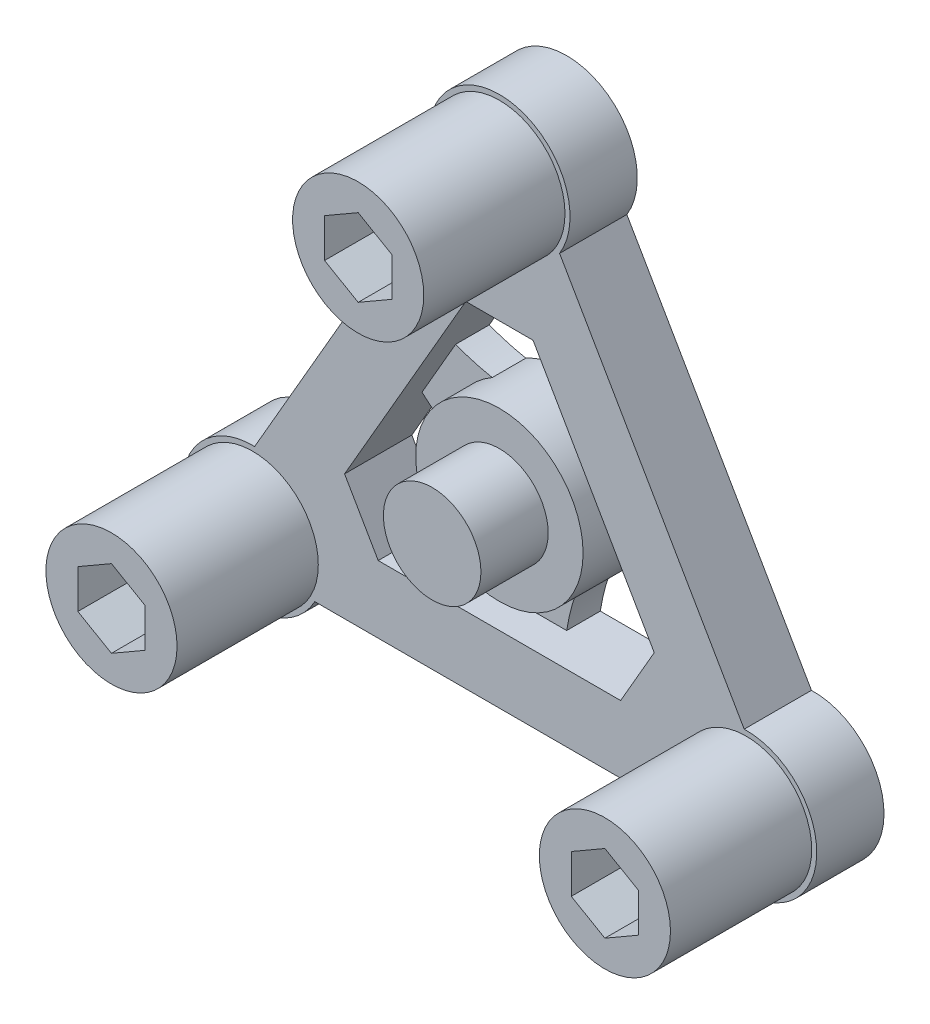
from build123d import *

# Parameters (mm, degrees)
BOSS_EXTRUDE1_DEPTH = 5
BOSS_EXTRUDE2_DEPTH = 5
SKETCH4_R           = 9.75
BOSS_EXTRUDE3_DEPTH = 21
BOSS_EXTRUDE4_START = -5
SKETCH5_R           = 12.441578391
BOSS_EXTRUDE4_DEPTH = 10
SKETCH5_3_R         = 7.25
BOSS_EXTRUDE5_DEPTH = 15
CHAMFER1_SIZE       = 10
CUT_EXTRUDE1_DEPTH  = 10
CUT_EXTRUDE2_DEPTH  = 4.2


with BuildPart() as part:
    # Sketch2 → Boss-Extrude1 (new body, symmetric)
    with BuildSketch(Plane.XY):
        with BuildLine():
            ThreePointArc((8.946673347, 36.860907204), (0, 52.857), (-8.946673347, 36.860907204))
            Line((-8.946673347, 36.860907204), (-36.395818719, -10.682407204))
            ThreePointArc((-36.395818719, -10.682407204), (-45.775504768, -26.4285), (-27.449145372, -26.1785))
            Line((-27.449145372, -26.1785), (27.449145372, -26.1785))
            ThreePointArc((27.449145372, -26.1785), (45.775504768, -26.4285), (36.395818719, -10.682407204))
            Line((36.395818719, -10.682407204), (8.946673347, 36.860907204))
        make_face()
        Polygon((-28.02198399, -16.1785), (0, 32.357), (28.02198399, -16.1785), align=None, mode=Mode.SUBTRACT)
    extrude(amount=BOSS_EXTRUDE1_DEPTH, both=True)

    # Sketch3 → Boss-Extrude2 (add)
    with BuildSketch(Plane.XY):
        with BuildLine():
            Line((-16.510991995, 3.759122981), (-11.510991995, 12.419377019))
            ThreePointArc((-11.510991995, 12.419377019), (0, 10.282645658), (11.510991995, 12.419377019))
            Line((11.510991995, 12.419377019), (16.510991995, 3.759122981))
            ThreePointArc((16.510991995, 3.759122981), (8.905032358, -5.141322829), (5, -16.1785))
            Line((5, -16.1785), (-5, -16.1785))
            ThreePointArc((-5, -16.1785), (-8.905032358, -5.141322829), (-16.510991995, 3.759122981))
        make_face()
    extrude(amount=-BOSS_EXTRUDE2_DEPTH)

    # Sketch4 → Boss-Extrude3 (add)
    with BuildSketch(Plane.XY.offset(5)):
        with Locations((-36.682238028, -21.1785)):
            Circle(SKETCH4_R)
        with Locations((36.682238028, -21.1785)):
            Circle(SKETCH4_R)
        with Locations((0, 42.357)):
            Circle(SKETCH4_R)
    extrude(amount=BOSS_EXTRUDE3_DEPTH)

    # Sketch5 → Boss-Extrude4 (add)
    with BuildSketch(Plane.XY.offset(BOSS_EXTRUDE4_START)):
        Circle(SKETCH5_R)
    extrude(amount=BOSS_EXTRUDE4_DEPTH)

    # Sketch5_3 → Boss-Extrude5 (add)
    with BuildSketch(Plane.XY):
        Circle(SKETCH5_3_R)
    extrude(amount=BOSS_EXTRUDE5_DEPTH)

    # Chamfer1
    chamfer1_edges = [part.edges().sort_by_distance(p)[0] for p in [
        (28.02198399, -16.1785, 0),
        (-28.02198399, -16.1785, 0),
        (0, 32.357, 0),
    ]]
    chamfer(chamfer1_edges, length=CHAMFER1_SIZE)

    # Sketch8 → Cut-Extrude1 (cut)
    with BuildSketch(Plane.XY.offset(26)):
        Polygon((-41.682238028, -24.065251346), (-36.682238028, -26.952002692), (-31.682238028, -24.065251346), (-31.682238028, -18.291748654), (-36.682238028, -15.404997308), (-41.682238028, -18.291748654), align=None)
        Polygon((41.682238028, -24.065251346), (41.682238028, -18.291748654), (36.682238028, -15.404997308), (31.682238028, -18.291748654), (31.682238028, -24.065251346), (36.682238028, -26.952002692), align=None)
        Polygon((0, 48.130502692), (-5, 45.243751346), (-5, 39.470248654), (0, 36.583497308), (5, 39.470248654), (5, 45.243751346), align=None)
    extrude(amount=-CUT_EXTRUDE1_DEPTH, mode=Mode.SUBTRACT)

    # Sketch10 → Cut-Extrude2 (cut)
    with BuildSketch(Plane(origin=(0, 0, -5), x_dir=(-1, 0, 0), z_dir=(0, 0, -1))):
        Polygon((9.381941874, 0), (4.690970937, 8.125), (-4.690970937, 8.125), (-9.381941874, 0), (-4.690970937, -8.125), (4.690970937, -8.125), align=None)
    extrude(amount=-CUT_EXTRUDE2_DEPTH, mode=Mode.SUBTRACT)


solid = part.part
